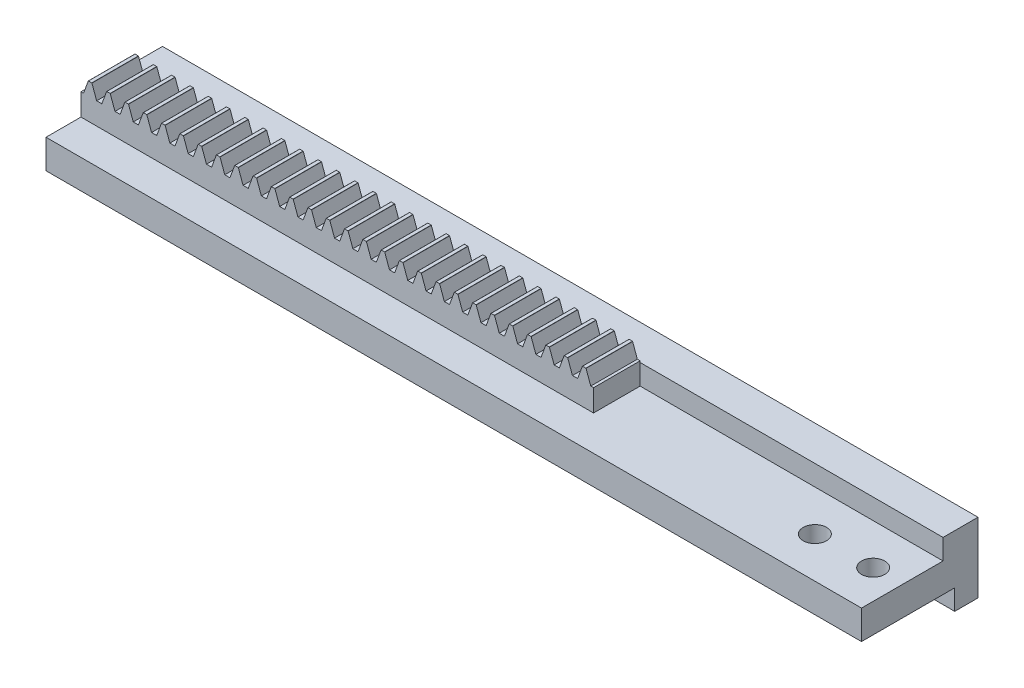
from build123d import *

# Parameters (mm, degrees)
BLANKSKE_W          = 70
BLANKSKE_H          = 3.5
BLANK_DEPTH         = 4
TOOTHCUTILL_DEPTH   = 71.201495711
TOOTHCUTSIM_DEPTH   = 71.201495711
TEETHCUTS_COUNT     = 33
TEETHCUTS_PITCH     = 1.570796325
BOSS_EXTRUDE1_DEPTH = 70
SKETCH4_W           = 70
SKETCH4_H           = 1.753065586
BOSS_EXTRUDE2_DEPTH = 1
SKETCH2_W           = 4
SKETCH2_H           = 3.006131172
CUT_EXTRUDE1_DEPTH  = 26
SKETCH3_R           = 1
CUT_EXTRUDE2_DEPTH  = 7.5


with BuildPart() as part:
    # BlankSke → Blank (new body)
    with BuildSketch(Plane.XY):
        with Locations((35, 1.75)):
            Rectangle(BLANKSKE_W, BLANKSKE_H)
    extrude(amount=-BLANK_DEPTH)

    # TooCutSkeIll → ToothCutIll (cut, through all)
    with BuildSketch(Plane.XY):
        with BuildLine():
            Line((-0.626894497, 3.486840403), (-0.252392805, 2.457905462))
            ThreePointArc((-0.252392805, 2.457905462), (-0.206262166, 2.397786842), (-0.133991535, 2.375))
            Line((-0.133991535, 2.375), (0.133991535, 2.375))
            ThreePointArc((0.133991535, 2.375), (0.206262166, 2.397786842), (0.252392805, 2.457905462))
            Line((0.252392805, 2.457905462), (0.626894497, 3.486840403))
            ThreePointArc((0.626894497, 3.486840403), (0.63421682, 3.496383041), (0.645688349, 3.5))
            Line((0.645688349, 3.5), (0.645688349, 3.5254))
            Line((0.645688349, 3.5254), (-0.645688349, 3.5254))
            Line((-0.645688349, 3.5254), (-0.645688349, 3.5))
            ThreePointArc((-0.645688349, 3.5), (-0.63421682, 3.496383041), (-0.626894497, 3.486840403))
        make_face()
    toothcutill = extrude(amount=-TOOTHCUTILL_DEPTH, mode=Mode.SUBTRACT)

    # TooCutSkeSim → ToothCutSim (cut, through all)
    with BuildSketch(Plane.XY):
        Polygon((0.222217685, 2.375), (-0.222217685, 2.375), (-0.640929042, 3.5254), (0.640929042, 3.5254), align=None)
    toothcutsim = extrude(amount=-TOOTHCUTSIM_DEPTH, mode=Mode.SUBTRACT)

    # TeethCuts: ToothCutIll, ToothCutSim ×33
    with Locations(*[(i * TEETHCUTS_PITCH, 0, 0) for i in range(1, TEETHCUTS_COUNT)]):
        add(toothcutill, mode=Mode.SUBTRACT)
        add(toothcutsim, mode=Mode.SUBTRACT)

    # Sketch1 → Boss-Extrude1 (add)
    with BuildSketch(Plane(origin=(70, 0, 0), x_dir=(0, 0, -1), z_dir=(1, 0, 0))):
        Polygon((0, 0.493868828), (-3, 0.493868828), (-3, -2), (0, -2), (4, -2), (5, -2), (5, -3.753065586), (7, -3.753065586), (7, 2.246934414), (5, 2.246934414), (5, 0.493868828), (4, 0.493868828), align=None)
    extrude(amount=-BOSS_EXTRUDE1_DEPTH)

    # Sketch4 → Boss-Extrude2 (add)
    with BuildSketch(Plane.XY.offset(-5)):
        with Locations((35, 1.370401621)):
            Rectangle(SKETCH4_W, SKETCH4_H)
    extrude(amount=BOSS_EXTRUDE2_DEPTH)

    # Sketch2 → Cut-Extrude1 (cut)
    with BuildSketch(Plane(origin=(70, 0, 0), x_dir=(0, 0, -1), z_dir=(1, 0, 0))):
        with Locations((2, 1.996934414)):
            Rectangle(SKETCH2_W, SKETCH2_H)
    extrude(amount=-CUT_EXTRUDE1_DEPTH, mode=Mode.SUBTRACT)

    # Sketch3 → Cut-Extrude2 (cut, symmetric)
    with BuildSketch(Plane(origin=(0, 0.493868828, 0), x_dir=(1, 0, 0), z_dir=(0, 1, 0))):
        with Locations(Location((67.5, 0.5, 0), (0, 0, 270))):
            Circle(SKETCH3_R)
        with Locations(Location((62.5, 0.5, 0), (0, 0, 270))):
            Circle(SKETCH3_R)
    extrude(amount=CUT_EXTRUDE2_DEPTH, both=True, mode=Mode.SUBTRACT)


solid = part.part
